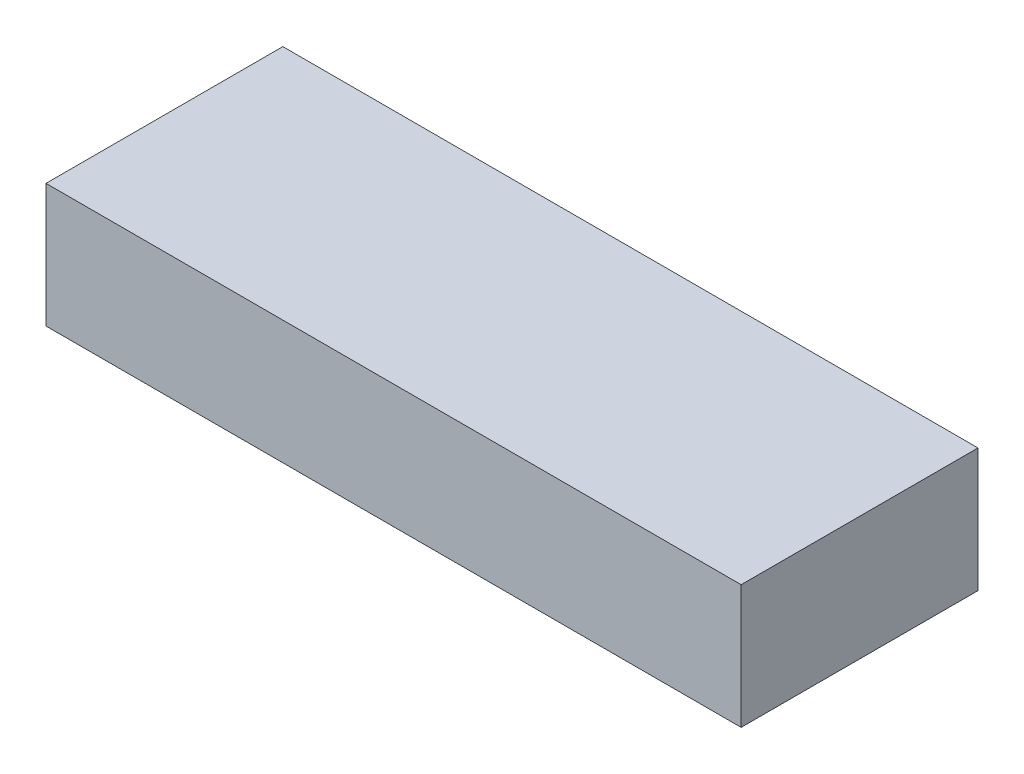
from build123d import *

# Parameters (mm, degrees)
SKETCH1_W           = 135
SKETCH1_H           = 46
BOSS_EXTRUDE1_DEPTH = 12


with BuildPart() as part:
    # Sketch1 → Boss-Extrude1 (new body, symmetric)
    with BuildSketch(Plane(origin=(0, 0, 0), x_dir=(1, 0, 0), z_dir=(0, 1, 0))):
        Rectangle(SKETCH1_W, SKETCH1_H)
    extrude(amount=BOSS_EXTRUDE1_DEPTH, both=True)


solid = part.part
